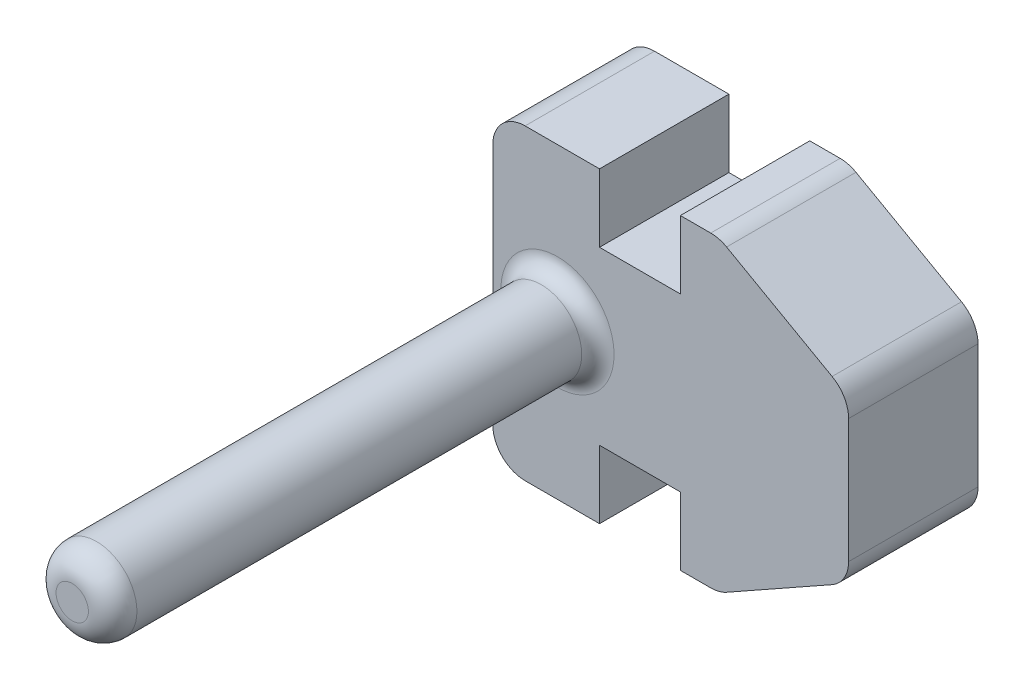
from build123d import *

# Parameters (mm, degrees)
BOSS_EXTRUDE1_DEPTH = 4
BOSS_EXTRUDE2_DEPTH = 4
SKETCH3_R           = 1.25
BOSS_EXTRUDE3_DEPTH = 15
FILLET1_R           = 1
FILLET2_R           = 0.5
FILLET3_R           = 0.75


with BuildPart() as part:
    # Sketch1 → Boss-Extrude1 (new body)
    with BuildSketch(Plane.XY):
        Polygon((2.3, -4.75), (3.5, -4.75), (3.5, 4.75), (2.3, 4.75), (2.3, 2.65), (-0.2, 2.65), (-0.2, 4.75), (-3.5, 4.75), (-3.5, -4.75), (-0.2, -4.75), (-0.2, -2.65), (2.3, -2.65), align=None)
    extrude(amount=BOSS_EXTRUDE1_DEPTH)

    # Sketch2 → Boss-Extrude2 (add)
    with BuildSketch(Plane(origin=(0, 0, 0), x_dir=(-1, 0, 0), z_dir=(0, 0, -1))):
        Polygon((-7.5, 2.5), (-7.5, -2.5), (-3.5, -4.75), (-3.5, 4.75), align=None)
    extrude(amount=-BOSS_EXTRUDE2_DEPTH)

    # Sketch3 → Boss-Extrude3 (add)
    with BuildSketch(Plane.XY.offset(4)):
        with Locations((-1.5, 0)):
            Circle(SKETCH3_R)
    extrude(amount=BOSS_EXTRUDE3_DEPTH)

    # Fillet1
    fillet1_edges = [part.edges().sort_by_distance(p)[0] for p in [
        (-3.5, -4.75, 2),
        (-3.5, 4.75, 2),
        (3.5, 4.75, 2),
        (3.5, -4.75, 2),
        (7.5, -2.5, 2),
        (7.5, 2.5, 2),
    ]]
    fillet(fillet1_edges, radius=FILLET1_R)

    # Fillet2
    fillet2_edges = [part.edges().sort_by_distance(p)[0] for p in [
        (-2.75, 0, 4),
    ]]
    fillet(fillet2_edges, radius=FILLET2_R)

    # Fillet3
    fillet3_edges = [part.edges().sort_by_distance(p)[0] for p in [
        (-2.75, 0, 19),
    ]]
    fillet(fillet3_edges, radius=FILLET3_R)


solid = part.part
